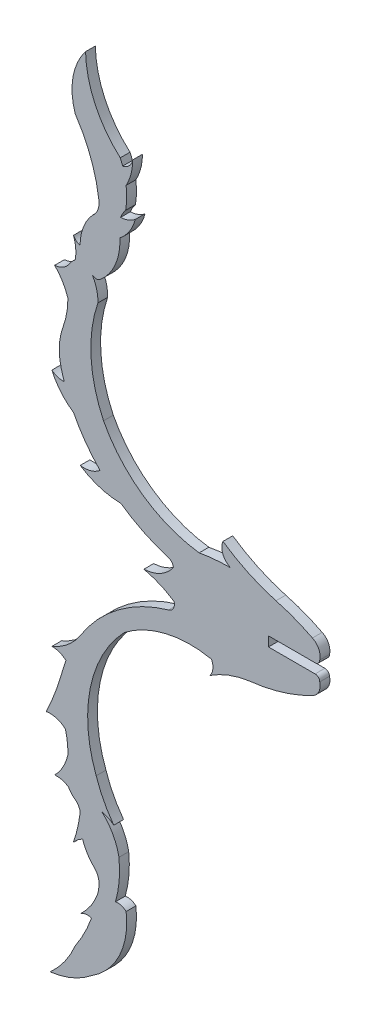
from build123d import *

# Parameters (mm, degrees)
BOSS_EXTRUDE1_DEPTH = 1.524


with BuildPart() as part:
    # Sketch1 → Boss-Extrude1 (new body)
    with BuildSketch(Plane.XY):
        with BuildLine():
            Line((-277.916022261, 935.884590671), (-285.203156616, 935.884606348))
            Line((-285.203156616, 935.884606348), (-285.203156616, 937.391012124))
            Line((-285.203156616, 937.391012124), (-277.916022261, 937.391027801))
            ThreePointArc((-277.916022261, 937.391027801), (-277.404732191, 937.602812049), (-277.192949044, 938.114102574))
            ThreePointArc((-277.192949044, 938.114102574), (-277.338273323, 939.523325046), (-278.333966376, 940.531106008))
            ThreePointArc((-278.333966376, 940.531106008), (-281.120669571, 941.782213098), (-284.027620805, 942.720625679))
            ThreePointArc((-284.027620805, 942.720625679), (-288.327575015, 944.323536073), (-292.30676806, 946.609351169))
            ThreePointArc((-292.30676806, 946.609351169), (-292.318053521, 944.881271306), (-291.117622598, 943.638149038))
            ThreePointArc((-291.117622598, 943.638149038), (-293.581810552, 943.528926691), (-296.026671847, 943.202116281))
            ThreePointArc((-296.026671847, 943.202116281), (-304.765117762, 946.571977556), (-310.958943201, 953.597141502))
            ThreePointArc((-310.958943201, 953.597141502), (-312.909914326, 961.259205892), (-311.83641056, 969.092539073))
            ThreePointArc((-311.83641056, 969.092539073), (-312.032754546, 970.855390285), (-312.723616891, 972.489068521))
            ThreePointArc((-312.723616891, 972.489068521), (-312.075442701, 972.234238525), (-311.427268511, 972.489068521))
            ThreePointArc((-311.427268511, 972.489068521), (-309.093003832, 975.689484265), (-308.423499884, 979.593740531))
            ThreePointArc((-308.423499884, 979.593740531), (-306.900843126, 981.252159973), (-305.996550373, 983.313977924))
            ThreePointArc((-305.996550373, 983.313977924), (-307.073192817, 982.682922072), (-308.296117566, 982.434234514))
            ThreePointArc((-308.296117566, 982.434234514), (-307.955705891, 983.149057367), (-307.497960974, 983.795061554))
            ThreePointArc((-307.497960974, 983.795061554), (-307.339448033, 985.49236907), (-307.429564156, 987.194678748))
            ThreePointArc((-307.429564156, 987.194678748), (-306.664530959, 989.110784639), (-306.404290892, 991.157492406))
            ThreePointArc((-306.404290892, 991.157492406), (-306.936605496, 990.101048934), (-307.973845227, 989.532220851))
            ThreePointArc((-307.973845227, 989.532220851), (-308.148188947, 990.005120957), (-308.342762435, 990.47006332))
            ThreePointArc((-308.342762435, 990.47006332), (-312.267081574, 995.727304596), (-313.766747643, 1002.113999219))
            ThreePointArc((-313.766747643, 1002.113999219), (-315.73298932, 997.693682682), (-315.365124744, 992.869785889))
            ThreePointArc((-315.365124744, 992.869785889), (-312.991611752, 988.301516567), (-311.716030786, 983.313977924))
            ThreePointArc((-311.716030786, 983.313977924), (-311.804694988, 981.790848195), (-312.68001538, 980.541208357))
            ThreePointArc((-312.68001538, 980.541208357), (-314.117806981, 978.199671225), (-314.619350909, 975.498098624))
            ThreePointArc((-314.619350909, 975.498098624), (-315.225884586, 975.805286829), (-315.64332213, 976.341937173))
            ThreePointArc((-315.64332213, 976.341937173), (-315.299209722, 974.750720167), (-315.381025476, 973.124777027))
            ThreePointArc((-315.381025476, 973.124777027), (-315.973449697, 972.588843997), (-316.436986467, 971.938210203))
            ThreePointArc((-316.436986467, 971.938210203), (-317.393086767, 971.150910263), (-318.584467297, 970.812411499))
            ThreePointArc((-318.584467297, 970.812411499), (-317.350697798, 969.220806246), (-316.518624321, 967.386944694))
            ThreePointArc((-316.518624321, 967.386944694), (-316.709257262, 965.229666664), (-317.275247771, 963.139249442))
            ThreePointArc((-317.275247771, 963.139249442), (-317.856536979, 960.284878164), (-317.558763157, 957.387178511))
            ThreePointArc((-317.558763157, 957.387178511), (-317.339657536, 956.598381541), (-317.094041757, 955.817432873))
            ThreePointArc((-317.094041757, 955.817432873), (-318.118043569, 955.930405975), (-319.022729617, 956.423240417))
            ThreePointArc((-319.022729617, 956.423240417), (-317.621338919, 954.158054516), (-315.64332213, 952.374122723))
            ThreePointArc((-315.64332213, 952.374122723), (-313.785435132, 949.339402014), (-311.503309748, 946.609351169))
            ThreePointArc((-311.503309748, 946.609351169), (-312.953347628, 945.841313107), (-314.591537057, 945.747357192))
            ThreePointArc((-314.591537057, 945.747357192), (-311.553116659, 944.299676635), (-308.227229789, 943.78367854))
            ThreePointArc((-308.227229789, 943.78367854), (-304.724383034, 941.692906178), (-300.920541819, 940.219116344))
            ThreePointArc((-300.920541819, 940.219116344), (-300.33247451, 939.844426317), (-300.035650029, 939.213465936))
            ThreePointArc((-300.035650029, 939.213465936), (-302.045043086, 937.407911663), (-304.647627414, 936.683866421))
            ThreePointArc((-304.647627414, 936.683866421), (-302.200371512, 935.891549854), (-299.94034594, 934.663090898))
            ThreePointArc((-299.94034594, 934.663090898), (-300.038049245, 933.69975054), (-300.79307234, 933.093523928))
            ThreePointArc((-300.79307234, 933.093523928), (-308.644427917, 929.185810881), (-314.591537057, 922.740200085))
            ThreePointArc((-314.591537057, 922.740200085), (-316.523960255, 920.558055545), (-319.022728662, 919.057332166))
            ThreePointArc((-319.022728662, 919.057332166), (-317.841309798, 918.862286718), (-316.819146135, 918.238608351))
            ThreePointArc((-316.819146135, 918.238608351), (-317.206321698, 917.112560154), (-317.537734191, 915.968857736))
            ThreePointArc((-317.537734191, 915.968857736), (-318.596134624, 912.830665778), (-319.922253722, 909.795889281))
            ThreePointArc((-319.922253722, 909.795889281), (-318.307455112, 909.712246343), (-316.897931891, 908.919898577))
            ThreePointArc((-316.897931891, 908.919898577), (-316.598343369, 907.286884178), (-316.521377997, 905.628401245))
            ThreePointArc((-316.521377997, 905.628401245), (-317.288501726, 903.611397757), (-318.584467297, 901.885925322))
            ThreePointArc((-318.584467297, 901.885925322), (-317.459455632, 901.812397156), (-316.436986467, 901.337408268))
            ThreePointArc((-316.436986467, 901.337408268), (-315.973449697, 900.686774475), (-315.381025476, 900.150841445))
            ThreePointArc((-315.381025476, 900.150841445), (-314.855793688, 899.575963976), (-314.600768516, 898.84022306))
            ThreePointArc((-314.600768516, 898.84022306), (-315.008341261, 896.492487869), (-315.677043026, 894.205390577))
            ThreePointArc((-315.677043026, 894.205390577), (-315.022224116, 894.879239219), (-314.227435144, 895.380408141))
            ThreePointArc((-314.227435144, 895.380408141), (-313.589841267, 893.977791631), (-312.679998267, 892.734391155))
            ThreePointArc((-312.679998267, 892.734391155), (-311.804692825, 891.484757082), (-311.716030786, 889.961640548))
            ThreePointArc((-311.716030786, 889.961640548), (-311.763791905, 889.630867843), (-311.816449784, 889.300839277))
            ThreePointArc((-311.816449784, 889.300839277), (-312.878083338, 887.113343117), (-314.444692648, 885.253789266))
            ThreePointArc((-314.444692648, 885.253789266), (-313.65384255, 885.493842794), (-312.832184374, 885.404694518))
            ThreePointArc((-312.832184374, 885.404694518), (-313.94276822, 882.826275412), (-315.365124744, 880.405832583))
            ThreePointArc((-315.365124744, 880.405832583), (-317.025672215, 877.438104616), (-319.293323049, 874.903822293))
            ThreePointArc((-319.293323049, 874.903822293), (-315.812908434, 875.83934739), (-312.728096674, 877.702792989))
            ThreePointArc((-312.728096674, 877.702792989), (-308.443902691, 882.584048211), (-307.427457693, 888.998704102))
            ThreePointArc((-307.427457693, 888.998704102), (-308.20314369, 889.43695462), (-309.093003832, 889.480557515))
            ThreePointArc((-309.093003832, 889.480557515), (-308.513125406, 892.598000293), (-308.54961586, 895.768706352))
            ThreePointArc((-308.54961586, 895.768706352), (-309.481516734, 898.387713723), (-311.193435925, 900.577912695))
            ThreePointArc((-311.193435925, 900.577912695), (-310.219823691, 900.257804208), (-309.354771115, 899.708191378))
            ThreePointArc((-309.354771115, 899.708191378), (-310.941483354, 902.250655609), (-312.100693339, 905.014351016))
            ThreePointArc((-312.100693339, 905.014351016), (-313.022128407, 916.44457007), (-307.699732777, 926.601885411))
            ThreePointArc((-307.699732777, 926.601885411), (-302.18443266, 929.41780767), (-296.026671847, 930.073502191))
            ThreePointArc((-296.026671847, 930.073502191), (-295.073187001, 929.919785137), (-294.114945931, 929.799218415))
            ThreePointArc((-294.114945931, 929.799218415), (-293.879713809, 928.583729022), (-294.369589284, 927.446728303))
            ThreePointArc((-294.369589284, 927.446728303), (-291.413219904, 928.960043614), (-288.197659122, 929.790953956))
            ThreePointArc((-288.197659122, 929.790953956), (-283.128142335, 930.80796962), (-278.333966376, 932.744512464))
            ThreePointArc((-278.333966376, 932.744512464), (-277.338273323, 933.752293426), (-277.192949044, 935.161515898))
            ThreePointArc((-277.192949044, 935.161515898), (-277.404732191, 935.672806423), (-277.916022261, 935.884590671))
        make_face()
    extrude(amount=BOSS_EXTRUDE1_DEPTH)


solid = part.part
